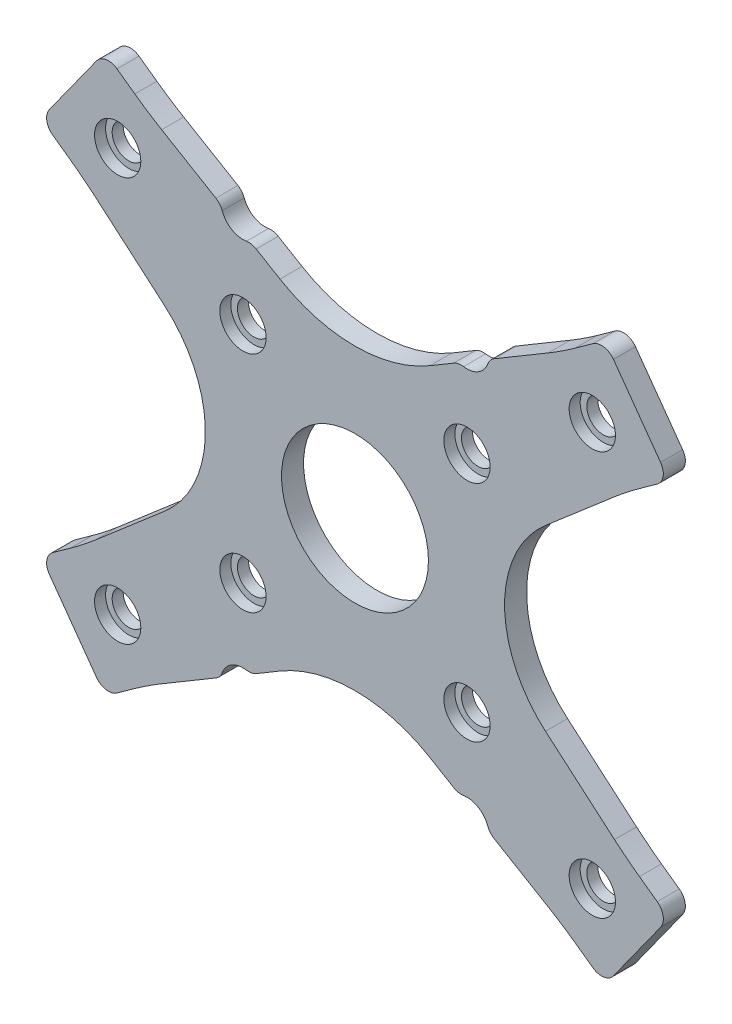
from build123d import *

# Parameters (mm, degrees)
SKETCH2_R                      = 10.000000005
BOSS_EXTRUDE1_DEPTH            = 3
CBORE_FOR_M4_SHCS1_D           = 4.5
CBORE_FOR_M4_SHCS1_DEPTH       = 3
CBORE_FOR_M4_SHCS1_CBORE_D     = 6.3
CBORE_FOR_M4_SHCS1_CBORE_DEPTH = 1.5


with BuildPart() as part:
    # Sketch2 → Boss-Extrude1 (new body)
    with BuildSketch(Plane.XY):
        with BuildLine():
            Line((-13.450392883, 25.031130473), (-10.20502672, 23.105662299))
            ThreePointArc((-10.20502672, 23.105662299), (-3.968e-06, 20.306168967), (10.205019894, 23.105658249))
            Line((10.205019894, 23.105658249), (13.450387996, 25.031127573))
            ThreePointArc((13.450387996, 25.031127573), (14.094139601, 25.275272827), (14.782538902, 25.286649864))
            ThreePointArc((14.782538902, 25.286649864), (16.78075793, 25.669928952), (18.074867487, 27.239980734))
            ThreePointArc((18.074867487, 27.239980734), (18.414792088, 27.838704748), (18.937607191, 28.286681921))
            Line((18.937607191, 28.286681921), (26.321935247, 32.667786531))
            ThreePointArc((26.321935247, 32.667786531), (28.173342154, 33.821556246), (29.972660204, 35.054985063))
            Line((29.972660204, 35.054985063), (32.400972322, 36.798655128))
            ThreePointArc((32.400972322, 36.798655128), (33.891380916, 37.14769377), (35.19206653, 36.340623337))
            Line((35.19206653, 36.340623337), (41.607988179, 27.405526841))
            ThreePointArc((41.607988179, 27.405526841), (41.957026821, 25.915118247), (41.149956388, 24.614432633))
            Line((41.149956388, 24.614432633), (38.721644271, 22.870762568))
            ThreePointArc((38.721644271, 22.870762568), (36.996358641, 21.574581735), (35.32860836, 20.205164245))
            Line((35.32860836, 20.205164245), (25.926777876, 12.123874069))
            ThreePointArc((25.926777876, 12.123874069), (20.367651625, -0.007528621), (25.938200134, -12.133690637))
            Line((25.938200134, -12.133690637), (35.328603735, -20.2051589))
            ThreePointArc((35.328603735, -20.2051589), (36.996354051, -21.574576424), (38.72163972, -22.870757287))
            Line((38.72163972, -22.870757287), (41.149951774, -24.614427306))
            ThreePointArc((41.149951774, -24.614427306), (41.957022207, -25.915112921), (41.607983565, -27.405521515))
            Line((41.607983565, -27.405521515), (35.192061916, -36.340618011))
            ThreePointArc((35.192061916, -36.340618011), (33.891376301, -37.147688443), (32.400967708, -36.798649801))
            Line((32.400967708, -36.798649801), (29.97265559, -35.054979737))
            ThreePointArc((29.97265559, -35.054979737), (28.17333754, -33.82155092), (26.321930633, -32.667781205))
            Line((26.321930633, -32.667781205), (18.937602577, -28.286676595))
            ThreePointArc((18.937602577, -28.286676595), (18.414787474, -27.838699422), (18.074862873, -27.239975407))
            ThreePointArc((18.074862873, -27.239975407), (16.780753316, -25.669923625), (14.782534288, -25.286644538))
            ThreePointArc((14.782534288, -25.286644538), (14.094137778, -25.275268036), (13.450388269, -25.031125147))
            Line((13.450388269, -25.031125147), (10.205810688, -23.106124837))
            ThreePointArc((10.205810688, -23.106124837), (0.000458475, -20.306166365), (-10.205022095, -23.105656954))
            Line((-10.205022095, -23.105656954), (-13.450388259, -25.031125129))
            ThreePointArc((-13.450388259, -25.031125129), (-14.094137767, -25.275268018), (-14.782534277, -25.28664452))
            ThreePointArc((-14.782534277, -25.28664452), (-16.780753305, -25.669923607), (-18.074862862, -27.239975389))
            ThreePointArc((-18.074862862, -27.239975389), (-18.414787463, -27.838699404), (-18.937602566, -28.286676577))
            Line((-18.937602566, -28.286676577), (-26.321930622, -32.667781187))
            ThreePointArc((-26.321930622, -32.667781187), (-28.173337529, -33.821550902), (-29.972655579, -35.054979718))
            Line((-29.972655579, -35.054979718), (-32.400967697, -36.798649783))
            ThreePointArc((-32.400967697, -36.798649783), (-33.891376291, -37.147688425), (-35.192061905, -36.340617993))
            Line((-35.192061905, -36.340617993), (-41.607983554, -27.405521497))
            ThreePointArc((-41.607983554, -27.405521497), (-41.957022196, -25.915112903), (-41.149951763, -24.614427288))
            Line((-41.149951763, -24.614427288), (-38.721639646, -22.870757224))
            ThreePointArc((-38.721639646, -22.870757224), (-36.996358678, -21.574576229), (-35.328612964, -20.2051589))
            Line((-35.328612964, -20.2051589), (-25.938209362, -12.133690637))
            ThreePointArc((-25.938209362, -12.133690637), (-20.367660853, -0.007528621), (-25.926787105, 12.123874069))
            Line((-25.926787105, 12.123874069), (-35.328617589, 20.205164245))
            ThreePointArc((-35.328617589, 20.205164245), (-36.996363303, 21.574581573), (-38.721644271, 22.870762568))
            Line((-38.721644271, 22.870762568), (-41.149956388, 24.614432633))
            ThreePointArc((-41.149956388, 24.614432633), (-41.957026821, 25.915118247), (-41.607988179, 27.405526841))
            Line((-41.607988179, 27.405526841), (-35.19206653, 36.340623337))
            ThreePointArc((-35.19206653, 36.340623337), (-33.891380916, 37.14769377), (-32.400972322, 36.798655128))
            Line((-32.400972322, 36.798655128), (-29.972660204, 35.054985063))
            ThreePointArc((-29.972660204, 35.054985063), (-28.173342154, 33.821556246), (-26.321935247, 32.667786531))
            Line((-26.321935247, 32.667786531), (-18.937607191, 28.286681921))
            ThreePointArc((-18.937607191, 28.286681921), (-18.414792088, 27.838704748), (-18.074867487, 27.239980734))
            ThreePointArc((-18.074867487, 27.239980734), (-16.78075793, 25.669928952), (-14.782538902, 25.286649864))
            ThreePointArc((-14.782538902, 25.286649864), (-14.094142392, 25.275273362), (-13.450392883, 25.031130473))
        make_face()
        Circle(SKETCH2_R, mode=Mode.SUBTRACT)
    extrude(amount=BOSS_EXTRUDE1_DEPTH)

    # CBORE for M4 SHCS1
    with Locations(Plane.XY.offset(3)):
        with Locations((-32.307911482, 27.498577675), (-15.249999989, 15.249999982), (-15.249999998, -15.250000005), (-32.307911482, -27.498577711), (15.249999989, 15.249999982), (32.307911482, 27.498577675), (32.307911482, -27.498577711), (15.249999998, -15.250000005)):
            CounterBoreHole(CBORE_FOR_M4_SHCS1_D / 2, CBORE_FOR_M4_SHCS1_CBORE_D / 2, CBORE_FOR_M4_SHCS1_CBORE_DEPTH, depth=CBORE_FOR_M4_SHCS1_DEPTH)


solid = part.part
